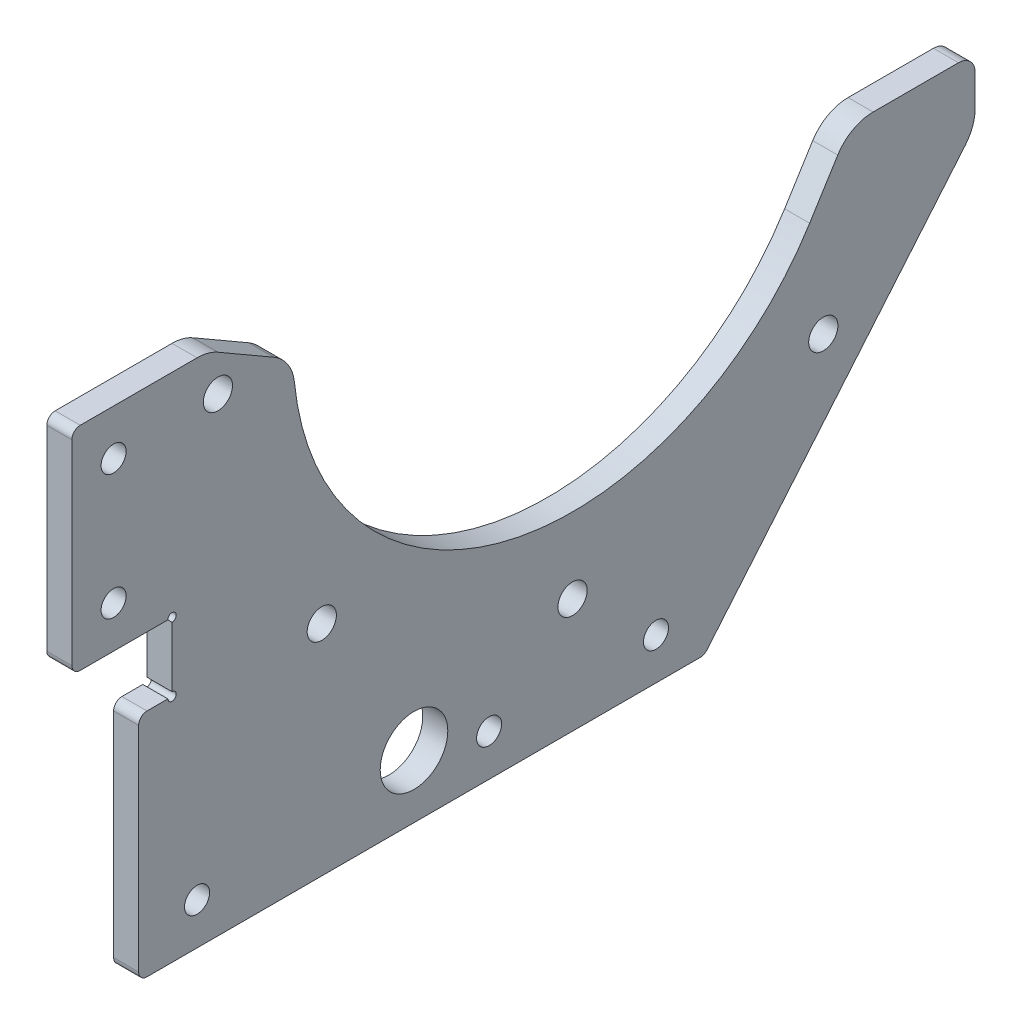
from build123d import *

# Parameters (mm, degrees)
SKETCH_1_R          = 1.5
SKETCH_1_R_2        = 1.75
EXTRUDE_1_DEPTH     = 3
FILLET_1_R          = 5
SKETCH_2_R          = 0.5
CUT_EXTRUDE_1_DEPTH = 10
FILLET_2_R          = 2
SKETCH_3_R          = 4.05
CUT_EXTRUDE_2_DEPTH = 10
FILLET_3_R          = 1


with BuildPart() as part:
    # 草图1 → 凸台-拉伸1 (new body)
    with BuildSketch(Plane(origin=(0, 0, 0), x_dir=(0, 0, -1), z_dir=(1, 0, 0))):
        with BuildLine():
            Line((-48, -20.45), (-48, -28.65))
            Line((-48, -28.65), (-52, -28.65))
            Line((-52, -28.65), (-52, -56.25))
            Line((-52, -56.25), (15.786547457, -56.25))
            Line((15.786547457, -56.25), (48.25, -17.561563803))
            Line((48.25, -17.561563803), (48.25, -10))
            Line((48.25, -10), (33.25, -10))
            Line((33.25, -10), (28.415845032, -17.74231527))
            ThreePointArc((28.415845032, -17.74231527), (-8.807963632, -32.321351714), (-33.488633754, -0.872587709))
            Line((-33.488633754, -0.872587709), (-43.660254038, 5))
            Line((-43.660254038, 5), (-60, 5))
            Line((-60, 5), (-60, -20.45))
            Line((-60, -20.45), (-48, -20.45))
        make_face()
        with Locations((-45, -51.25)):
            Circle(SKETCH_1_R, mode=Mode.SUBTRACT)
        with Locations((-10, -51.25)):
            Circle(SKETCH_1_R, mode=Mode.SUBTRACT)
        with Locations((-30.0520382, -30.0520382)):
            Circle(SKETCH_1_R_2, mode=Mode.SUBTRACT)
        with Locations((10, -51.25)):
            Circle(SKETCH_1_R, mode=Mode.SUBTRACT)
        with Locations((0, -42.5)):
            Circle(SKETCH_1_R_2, mode=Mode.SUBTRACT)
        with Locations((30.0520382, -30.0520382)):
            Circle(SKETCH_1_R_2, mode=Mode.SUBTRACT)
        with Locations((-55, -15.45)):
            Circle(SKETCH_1_R, mode=Mode.SUBTRACT)
        with Locations((-55, -0.45)):
            Circle(SKETCH_1_R, mode=Mode.SUBTRACT)
        with Locations((-42.5, 0)):
            Circle(SKETCH_1_R_2, mode=Mode.SUBTRACT)
    extrude(amount=EXTRUDE_1_DEPTH)

    # 圆角1
    fillet_1_edges = [part.edges().sort_by_distance(p)[0] for p in [
        (1.5, -10, -33.25),
        (1.5, -17.561563803, -48.25),
        (1.5, 5, 43.660254038),
        (1.5, -0.872587709, 33.488633754),
    ]]
    fillet(fillet_1_edges, radius=FILLET_1_R)

    # 草图2 → 切除-拉伸1 (cut)
    with BuildSketch(Plane.ZY):
        with Locations((48, -20.45)):
            Circle(SKETCH_2_R)
        with Locations((48, -28.65)):
            Circle(SKETCH_2_R)
    extrude(amount=-CUT_EXTRUDE_1_DEPTH, mode=Mode.SUBTRACT)

    # 圆角2
    fillet_2_edges = [part.edges().sort_by_distance(p)[0] for p in [
        (1.5, -10, -48.25),
    ]]
    fillet(fillet_2_edges, radius=FILLET_2_R)

    # 草图3 → 切除-拉伸2 (cut)
    with BuildSketch(Plane.ZY):
        with Locations((19, -48.75)):
            Circle(SKETCH_3_R)
    extrude(amount=-CUT_EXTRUDE_2_DEPTH, mode=Mode.SUBTRACT)

    # 圆角3
    fillet_3_edges = [part.edges().sort_by_distance(p)[0] for p in [
        (1.5, -56.25, -15.786547457),
        (1.5, -56.25, 52),
        (1.5, -28.65, 52),
        (1.5, -20.45, 60),
        (1.5, 5, 60),
    ]]
    fillet(fillet_3_edges, radius=FILLET_3_R)


solid = part.part
